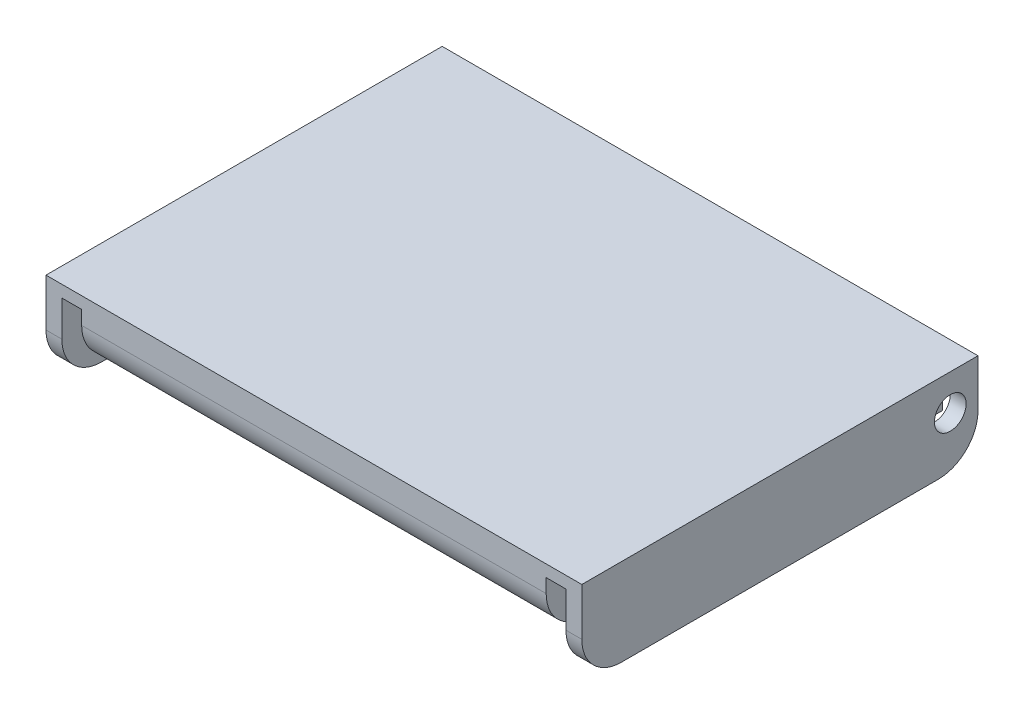
from build123d import *

# Parameters (mm, degrees)
SKETCH1_W           = 135.25
SKETCH1_H           = 100
BOSS_EXTRUDE1_DEPTH = 22
SKETCH4_W           = 5
SKETCH4_H           = 19
CUT_EXTRUDE1_DEPTH  = 101
SKETCH5_W           = 117.25
SKETCH5_H           = 11
CUT_EXTRUDE2_DEPTH  = 101
FILLET1_R           = 10
FILLET2_R           = 10
FILLET3_R           = 10
FILLET4_R           = 10
FILLET5_R           = 10
SKETCH6_R           = 4
CUT_EXTRUDE3_DEPTH  = 136.25


with BuildPart() as part:
    # Sketch1 → Boss-Extrude1 (new body)
    with BuildSketch(Plane(origin=(0, 0, 0), x_dir=(1, 0, 0), z_dir=(0, 1, 0))):
        Rectangle(SKETCH1_W, SKETCH1_H)
    extrude(amount=BOSS_EXTRUDE1_DEPTH)

    # Sketch4 → Cut-Extrude1 (cut, through all)
    with BuildSketch(Plane.XY.offset(50)):
        with Locations((-61.125, 9.5)):
            Rectangle(SKETCH4_W, SKETCH4_H)
        with Locations((61.125, 9.5)):
            Rectangle(SKETCH4_W, SKETCH4_H)
    extrude(amount=-CUT_EXTRUDE1_DEPTH, mode=Mode.SUBTRACT)

    # Sketch5 → Cut-Extrude2 (cut, through all)
    with BuildSketch(Plane(origin=(0, 0, -50), x_dir=(-1, 0, 0), z_dir=(0, 0, -1))):
        Rectangle(SKETCH5_W, SKETCH5_H)
    extrude(amount=-CUT_EXTRUDE2_DEPTH, mode=Mode.SUBTRACT)

    # Fillet1
    fillet1_edges = [part.edges().sort_by_distance(p)[0] for p in [
        (0, 5.5, 50),
    ]]
    fillet(fillet1_edges, radius=FILLET1_R)

    # Fillet2
    fillet2_edges = [part.edges().sort_by_distance(p)[0] for p in [
        (-65.625, 0, 50),
    ]]
    fillet(fillet2_edges, radius=FILLET2_R)

    # Fillet3
    fillet3_edges = [part.edges().sort_by_distance(p)[0] for p in [
        (65.625, 0, 50),
    ]]
    fillet(fillet3_edges, radius=FILLET3_R)

    # Fillet4
    fillet4_edges = [part.edges().sort_by_distance(p)[0] for p in [
        (-65.625, 0, -50),
    ]]
    fillet(fillet4_edges, radius=FILLET4_R)

    # Fillet5
    fillet5_edges = [part.edges().sort_by_distance(p)[0] for p in [
        (65.625, 0, -50),
    ]]
    fillet(fillet5_edges, radius=FILLET5_R)

    # Sketch6 → Cut-Extrude3 (cut, through all)
    with BuildSketch(Plane.ZY.offset(67.625)):
        with Locations((-43, 13)):
            Circle(SKETCH6_R)
    extrude(amount=-CUT_EXTRUDE3_DEPTH, mode=Mode.SUBTRACT)


solid = part.part
